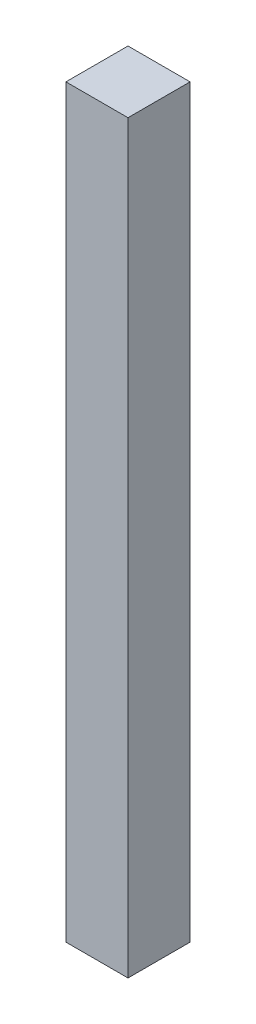
from build123d import *

# Parameters (mm, degrees)
SKETCH1_W           = 25.4
SKETCH1_H           = 25.4
BOSS_EXTRUDE1_DEPTH = 304.8


with BuildPart() as part:
    # Sketch1 → Boss-Extrude1 (new body)
    with BuildSketch(Plane(origin=(0, 0, 0), x_dir=(1, 0, 0), z_dir=(0, 1, 0))):
        with Locations((6.032056099, -7.339964805)):
            Rectangle(SKETCH1_W, SKETCH1_H)
    extrude(amount=BOSS_EXTRUDE1_DEPTH)


solid = part.part
